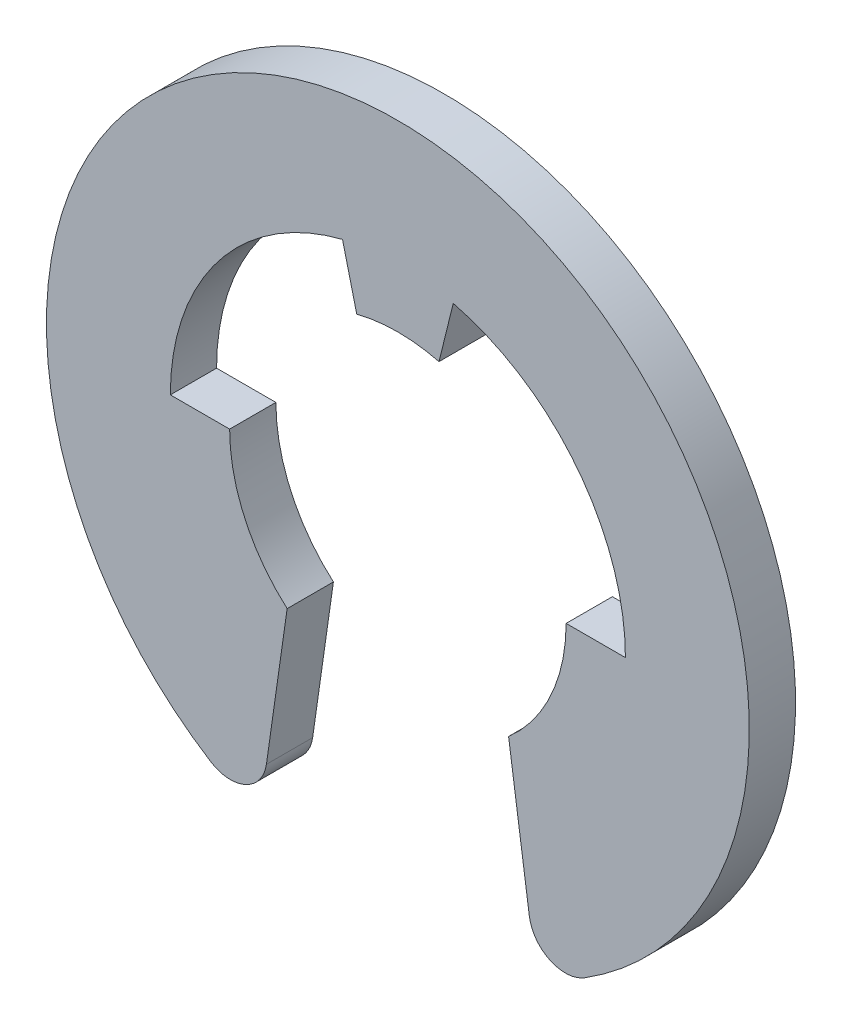
from build123d import *

# Parameters (mm, degrees)
BOSS_EXTRUDE1_DEPTH = 0.3175


with BuildPart() as part:
    # Sketch1 → Boss-Extrude1 (new body, symmetric)
    with BuildSketch(Plane.XY):
        with BuildLine():
            Line((-2.31, 0), (-3.124160712, 0))
            ThreePointArc((-3.124160712, 0), (-2.463203432, 1.921720325), (-0.76, 3.030310241))
            Line((-0.76, 3.030310241), (-0.565, 2.239838164))
            ThreePointArc((-0.565, 2.239838164), (0, 2.31), (0.565, 2.239838164))
            Line((0.565, 2.239838164), (0.76, 3.030310241))
            ThreePointArc((0.76, 3.030310241), (2.463203432, 1.921720325), (3.124160712, 0))
            Line((3.124160712, 0), (2.31, 0))
            ThreePointArc((2.31, 0), (2.103247489, -0.955222487), (1.52, -1.739453937))
            Line((1.52, -1.739453937), (1.80501504, -3.733492135))
            ThreePointArc((1.80501504, -3.733492135), (2.089707078, -4.11637794), (2.565878648, -4.086183031))
            ThreePointArc((2.565878648, -4.086183031), (0, 4.825), (-2.565878648, -4.086183031))
            ThreePointArc((-2.565878648, -4.086183031), (-2.089707078, -4.11637794), (-1.80501504, -3.733492135))
            Line((-1.80501504, -3.733492135), (-1.52, -1.739453937))
            ThreePointArc((-1.52, -1.739453937), (-2.103247489, -0.955222487), (-2.31, 0))
        make_face()
    extrude(amount=BOSS_EXTRUDE1_DEPTH, both=True)


solid = part.part
